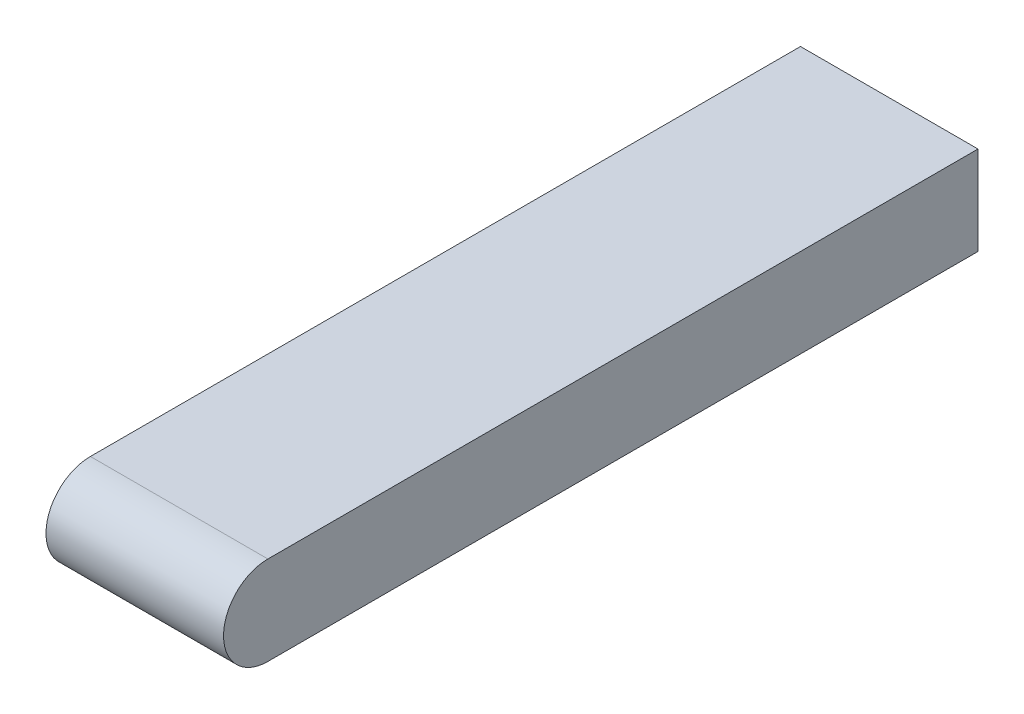
from build123d import *

# Parameters (mm, degrees)
BOSS_EXTRUDE1_DEPTH = 25.4


with BuildPart() as part:
    # Sketch1 → Boss-Extrude1 (new body)
    with BuildSketch(Plane(origin=(0, 0, 0), x_dir=(0, 0, -1), z_dir=(1, 0, 0))):
        with BuildLine():
            Line((0, -6.35), (88.9, -6.35))
            Line((88.9, -6.35), (88.9, 6.35))
            Line((88.9, 6.35), (0, 6.35))
            Line((0, 6.35), (-12.7, 6.35))
            ThreePointArc((-12.7, 6.35), (-19.05, 0), (-12.7, -6.35))
            Line((-12.7, -6.35), (0, -6.35))
        make_face()
    extrude(amount=BOSS_EXTRUDE1_DEPTH)


solid = part.part
